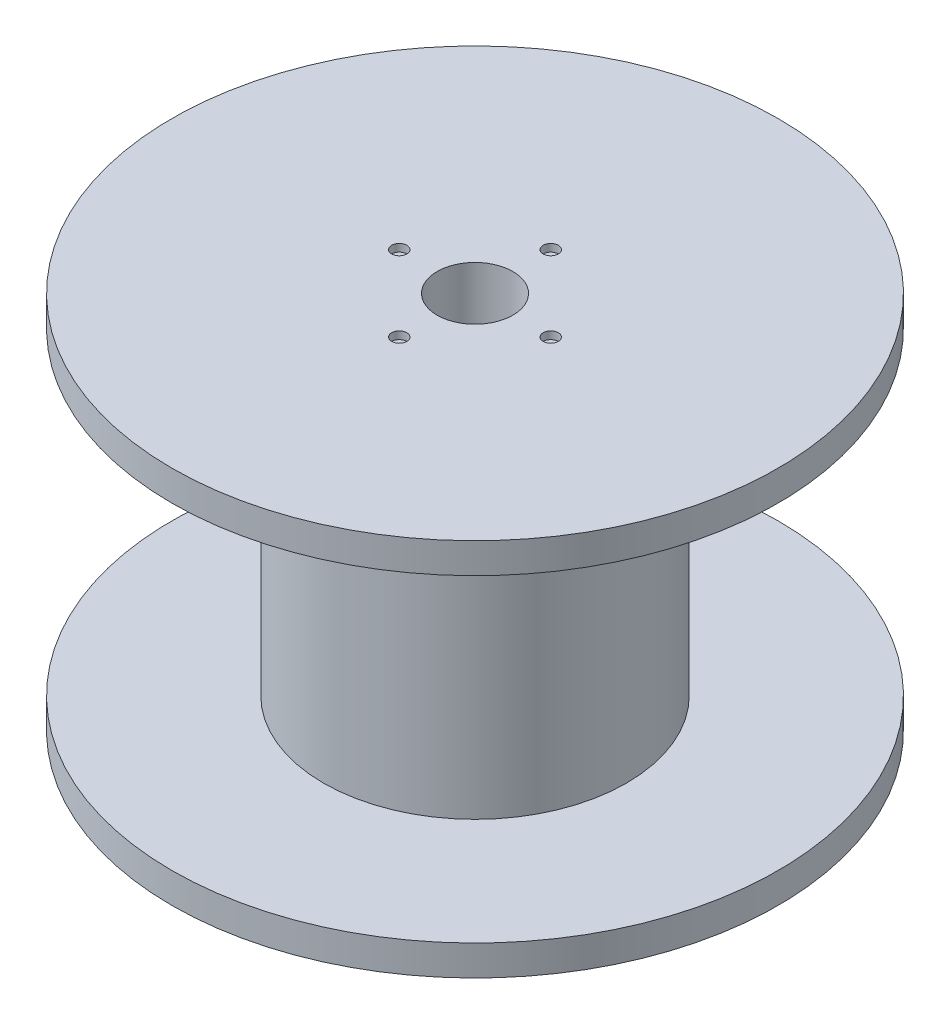
from build123d import *

# Parameters (mm, degrees)
CROQUIS1_R              = 10
SALIENTE_EXTRUIR1_DEPTH = 25
CROQUIS2_R              = 20
SALIENTE_EXTRUIR2_DEPTH = 2
SALIENTE_EXTRUIR3_START = -23
CROQUIS2_2_R            = 20
SALIENTE_EXTRUIR3_DEPTH = 2
CROQUIS3_R              = 2.5
CORTAR_EXTRUIR1_DEPTH   = 38.749172176
CROQUIS4_R              = 0.5
CORTAR_EXTRUIR2_DEPTH   = 0.5
CORTAR_EXTRUIR3_START   = -24.5
CROQUIS4_2_R            = 0.5
CORTAR_EXTRUIR3_DEPTH   = 0.5


with BuildPart() as part:
    # Croquis1 → Saliente-Extruir1 (new body)
    with BuildSketch(Plane(origin=(0, 0, 0), x_dir=(1, 0, 0), z_dir=(0, 1, 0))):
        Circle(CROQUIS1_R)
    extrude(amount=SALIENTE_EXTRUIR1_DEPTH)

    # Croquis2 → Saliente-Extruir2 (add)
    with BuildSketch(Plane(origin=(0, 25, 0), x_dir=(1, 0, 0), z_dir=(0, 1, 0))):
        Circle(CROQUIS2_R)
    extrude(amount=-SALIENTE_EXTRUIR2_DEPTH)

    # Croquis2_2 → Saliente-Extruir3 (add)
    with BuildSketch(Plane(origin=(0, 25, 0), x_dir=(1, 0, 0), z_dir=(0, 1, 0)).offset(SALIENTE_EXTRUIR3_START)):
        Circle(CROQUIS2_2_R)
    extrude(amount=-SALIENTE_EXTRUIR3_DEPTH)

    # Croquis3 → Cortar-Extruir1 (cut, through all)
    with BuildSketch(Plane(origin=(0, 25, 0), x_dir=(1, 0, 0), z_dir=(0, 1, 0))):
        Circle(CROQUIS3_R)
    extrude(amount=-CORTAR_EXTRUIR1_DEPTH, mode=Mode.SUBTRACT)

    # Croquis4 → Cortar-Extruir2 (cut)
    with BuildSketch(Plane(origin=(0, 25, 0), x_dir=(1, 0, 0), z_dir=(0, 1, 0))):
        with Locations((0, 5)):
            Circle(CROQUIS4_R)
        with Locations((5, 0)):
            Circle(CROQUIS4_R)
        with Locations((0, -5)):
            Circle(CROQUIS4_R)
        with Locations((-5, 0)):
            Circle(CROQUIS4_R)
    extrude(amount=-CORTAR_EXTRUIR2_DEPTH, mode=Mode.SUBTRACT)

    # Croquis4_2 → Cortar-Extruir3 (cut)
    with BuildSketch(Plane(origin=(0, 25, 0), x_dir=(1, 0, 0), z_dir=(0, 1, 0)).offset(CORTAR_EXTRUIR3_START)):
        with Locations((0, 5)):
            Circle(CROQUIS4_2_R)
        with Locations((5, 0)):
            Circle(CROQUIS4_2_R)
        with Locations((0, -5)):
            Circle(CROQUIS4_2_R)
        with Locations((-5, 0)):
            Circle(CROQUIS4_2_R)
    extrude(amount=-CORTAR_EXTRUIR3_DEPTH, mode=Mode.SUBTRACT)


solid = part.part
